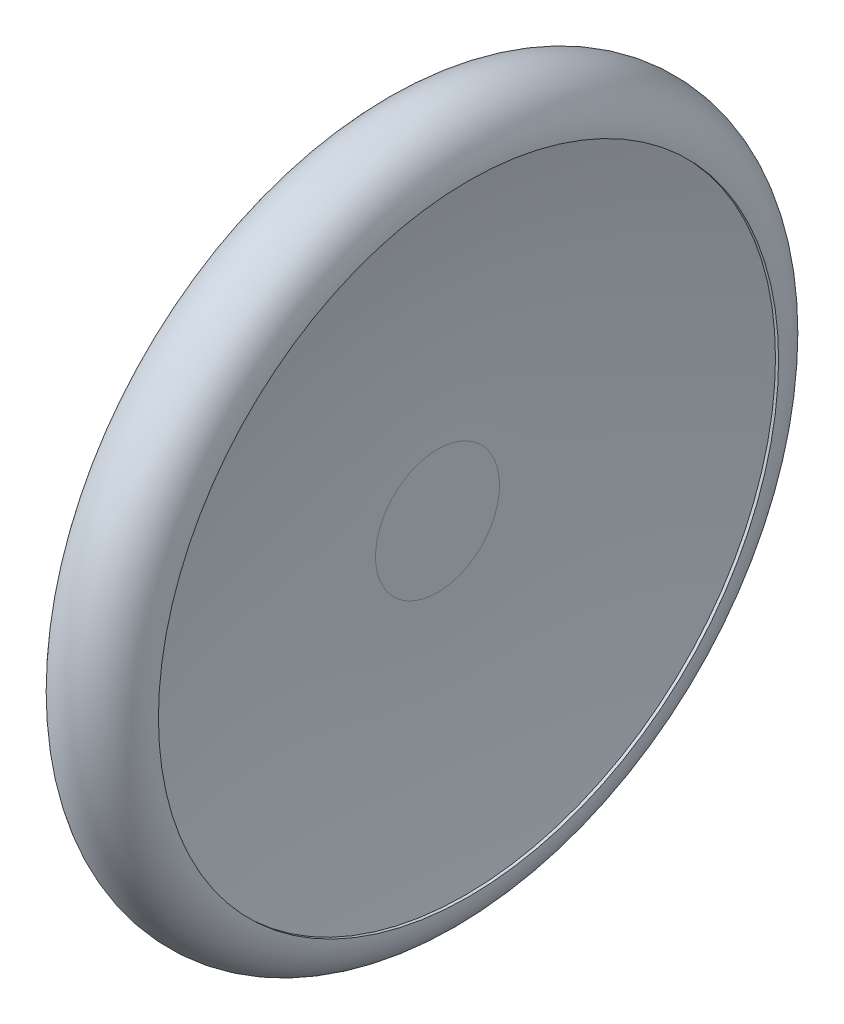
from build123d import *

# Parameters (mm, degrees)
SKETCH3_R           = 10
BOSS_EXTRUDE1_DEPTH = 10


with BuildPart() as part:
    # Sketch2 → Revolve1 (revolve)
    with BuildSketch(Plane.XY):
        with BuildLine():
            Line((-5, 0), (5, 0))
            Line((5, 0), (5, 10))
            ThreePointArc((5, 10), (6.128537222, 30.126164563), (9.5, 50))
            Line((9.5, 50), (10, 50))
            ThreePointArc((10, 50), (2.5, 57.5), (-5, 50))
            Line((-5, 50), (-5, 0))
        make_face()
    revolve(axis=Axis((-5, 0, 0), (1, 0, 0)))

    # Sketch3 → Boss-Extrude1 (add)
    with BuildSketch(Plane.ZY.offset(5)):
        Circle(SKETCH3_R)
    extrude(amount=BOSS_EXTRUDE1_DEPTH)


solid = part.part
